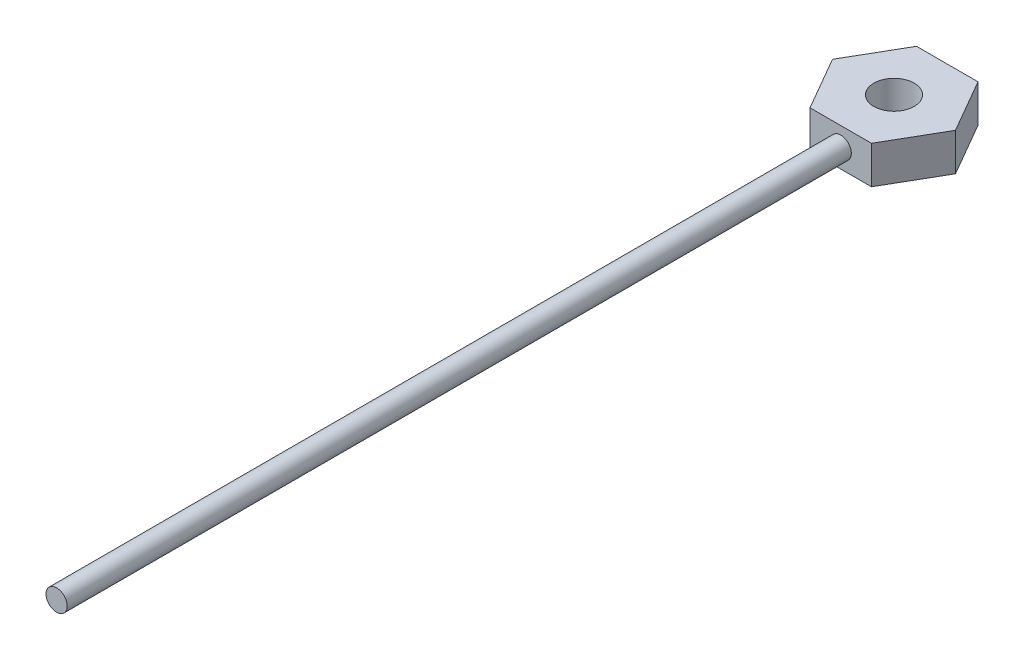
from build123d import *

# Parameters (mm, degrees)
CROQUIS1_R                 = 4.825
SALIENTE_EXTRUIR1_DEPTH    = 9
CROQUIS2_R                 = 2.53
SALIENTE_EXTRUIR2_DEPTH    = 200
CROQUIS3_R                 = 4.825
CORTAR_EXTRUIR1_DEPTH      = 29
CORTAR_EXTRUIR1_DEPTH_BACK = 67


with BuildPart() as part:
    # Croquis1 → Saliente-Extruir1 (new body)
    with BuildSketch(Plane(origin=(0, 0, 0), x_dir=(1, 0, 0), z_dir=(0, 1, 0))):
        Polygon((14.68670308, 0), (7.34335154, 12.719057965), (-7.34335154, 12.719057965), (-14.68670308, 0), (-7.34335154, -12.719057965), (7.34335154, -12.719057965), align=None)
        Circle(CROQUIS1_R, mode=Mode.SUBTRACT)
    extrude(amount=SALIENTE_EXTRUIR1_DEPTH)

    # Croquis2 → Saliente-Extruir2 (add)
    with BuildSketch(Plane.XY):
        with Locations((0, 4.5)):
            Circle(CROQUIS2_R)
    extrude(amount=SALIENTE_EXTRUIR2_DEPTH)

    # Croquis3 → Cortar-Extruir1 (cut, two sides)
    with BuildSketch(Plane(origin=(0, 0, 0), x_dir=(1, 0, 0), z_dir=(0, 1, 0))) as cortar_extruir1_sk:
        Circle(CROQUIS3_R)
    extrude(amount=CORTAR_EXTRUIR1_DEPTH, mode=Mode.SUBTRACT)
    extrude(cortar_extruir1_sk.sketch, amount=-CORTAR_EXTRUIR1_DEPTH_BACK, mode=Mode.SUBTRACT)


solid = part.part
